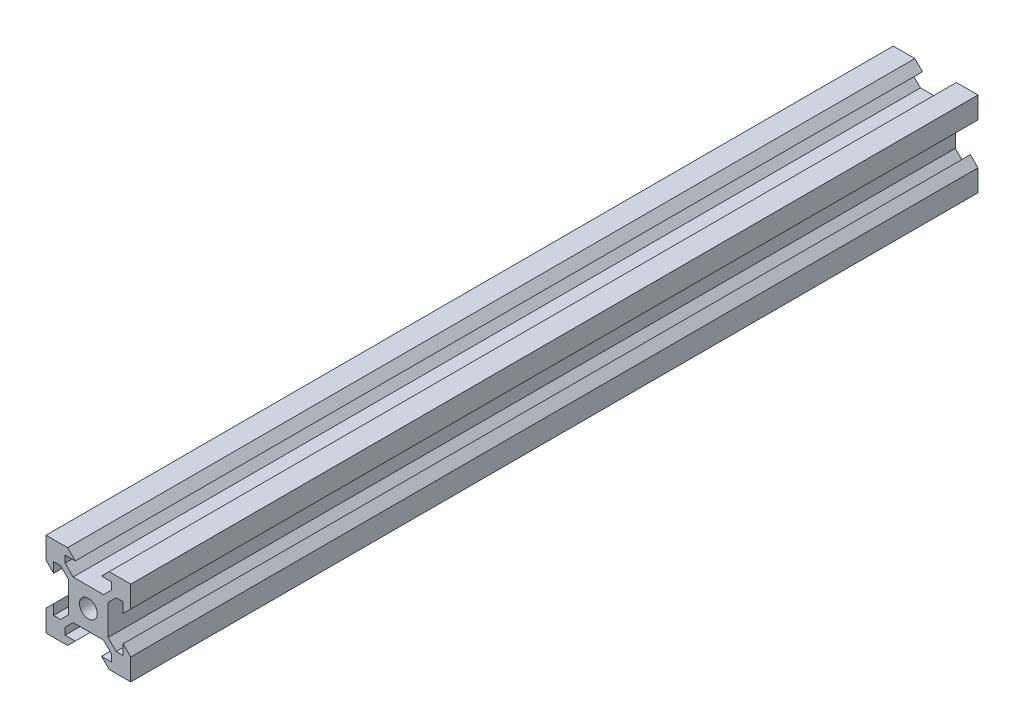
from build123d import *

# Parameters (mm, degrees)
SKETCH1_R           = 2.1
BOSS_EXTRUDE1_DEPTH = 100


with BuildPart() as part:
    # Sketch1 → Boss-Extrude1 (new body, symmetric)
    with BuildSketch(Plane.XY):
        Polygon((5.499339828, 6.56), (3.59, 4.650660172), (-3.59, 4.650660172), (-5.499339828, 6.56), (-5.499339828, 8.2), (-3.1, 8.2), (-4.9, 10), (-10, 10), (-10, 4.9), (-8.2, 3.1), (-8.2, 5.499339828), (-6.56, 5.499339828), (-4.650660172, 3.59), (-4.650660172, -3.59), (-6.56, -5.499339828), (-8.2, -5.499339828), (-8.2, -3.1), (-10, -4.9), (-10, -10), (-4.9, -10), (-3.1, -8.2), (-5.499339828, -8.2), (-5.499339828, -6.56), (-3.59, -4.650660172), (3.59, -4.650660172), (5.499339828, -6.56), (5.499339828, -8.2), (3.1, -8.2), (4.9, -10), (10, -10), (10, -4.9), (8.2, -3.1), (8.2, -5.499339828), (6.56, -5.499339828), (4.650660172, -3.59), (4.650660172, 3.59), (6.56, 5.499339828), (8.2, 5.499339828), (8.2, 3.1), (10, 4.9), (10, 10), (4.9, 10), (3.1, 8.2), (5.499339828, 8.2), align=None)
        Circle(SKETCH1_R, mode=Mode.SUBTRACT)
    extrude(amount=BOSS_EXTRUDE1_DEPTH, both=True)


solid = part.part
